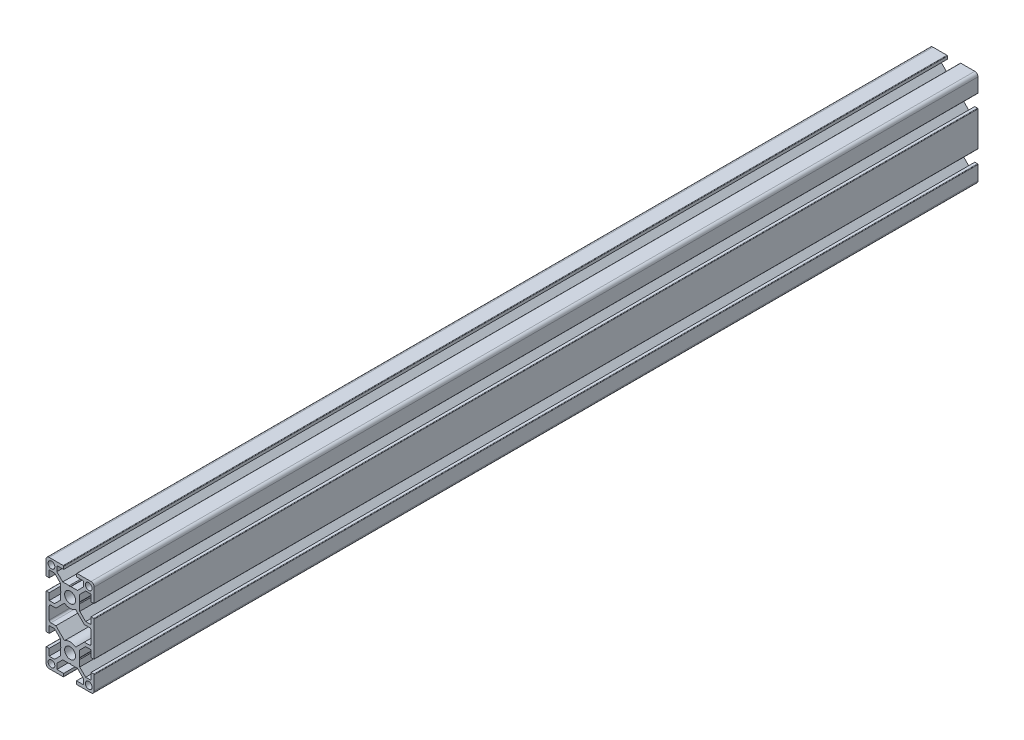
from build123d import *

# Parameters (mm, degrees)
SKETCH1_R           = 2.1
SKETCH1_R_2         = 3.4
BOSS_EXTRUDE1_DEPTH = 550


with BuildPart() as part:
    # Sketch1 → Boss-Extrude1 (new body)
    with BuildSketch(Plane(origin=(0, 0, -1000), x_dir=(-1, 0, 0), z_dir=(0, 0, -1))):
        with BuildLine():
            Line((15, -28), (15, -19.3))
            ThreePointArc((15, -19.3), (14.912132034, -19.087867966), (14.7, -19))
            Line((14.7, -19), (13, -19))
            Line((13, -19), (13, -23.25))
            Line((13, -23.25), (9.6642, -23.25))
            Line((9.6642, -23.25), (6, -19.5858))
            Line((6, -19.5858), (6, -15.519615242))
            Line((6, -15.519615242), (5.7, -15))
            Line((5.7, -15), (6, -14.480384758))
            Line((6, -14.480384758), (6, -10.4142))
            Line((6, -10.4142), (9.6642, -6.75))
            Line((9.6642, -6.75), (13, -6.75))
            Line((13, -6.75), (13, -11))
            Line((13, -11), (14.7, -11))
            ThreePointArc((14.7, -11), (14.912132034, -10.912132034), (15, -10.7))
            Line((15, -10.7), (15, 10.7))
            ThreePointArc((15, 10.7), (14.912132034, 10.912132034), (14.7, 11))
            Line((14.7, 11), (13, 11))
            Line((13, 11), (13, 6.75))
            Line((13, 6.75), (9.6642, 6.75))
            Line((9.6642, 6.75), (6, 10.4142))
            Line((6, 10.4142), (6, 14.480384758))
            Line((6, 14.480384758), (5.7, 15))
            Line((5.7, 15), (6, 15.519615242))
            Line((6, 15.519615242), (6, 19.5858))
            Line((6, 19.5858), (9.6642, 23.25))
            Line((9.6642, 23.25), (13, 23.25))
            Line((13, 23.25), (13, 19))
            Line((13, 19), (14.7, 19))
            ThreePointArc((14.7, 19), (14.912132034, 19.087867966), (15, 19.3))
            Line((15, 19.3), (15, 28))
            ThreePointArc((15, 28), (14.414213562, 29.414213562), (13, 30))
            Line((13, 30), (4.3, 30))
            ThreePointArc((4.3, 30), (4.087867966, 29.912132034), (4, 29.7))
            Line((4, 29.7), (4, 28))
            Line((4, 28), (8.25, 28))
            Line((8.25, 28), (8.25, 24.6642))
            Line((8.25, 24.6642), (4.5858, 21))
            Line((4.5858, 21), (0.519615242, 21))
            Line((0.519615242, 21), (0, 20.7))
            Line((0, 20.7), (-0.519615242, 21))
            Line((-0.519615242, 21), (-4.5858, 21))
            Line((-4.5858, 21), (-8.25, 24.6642))
            Line((-8.25, 24.6642), (-8.25, 28))
            Line((-8.25, 28), (-4, 28))
            Line((-4, 28), (-4, 29.7))
            ThreePointArc((-4, 29.7), (-4.087867966, 29.912132034), (-4.3, 30))
            Line((-4.3, 30), (-13, 30))
            ThreePointArc((-13, 30), (-14.414213562, 29.414213562), (-15, 28))
            Line((-15, 28), (-15, 19.3))
            ThreePointArc((-15, 19.3), (-14.912132034, 19.087867966), (-14.7, 19))
            Line((-14.7, 19), (-13, 19))
            Line((-13, 19), (-13, 23.25))
            Line((-13, 23.25), (-9.6642, 23.25))
            Line((-9.6642, 23.25), (-6, 19.5858))
            Line((-6, 19.5858), (-6, 15.519615242))
            Line((-6, 15.519615242), (-5.7, 15))
            Line((-5.7, 15), (-6, 14.480384758))
            Line((-6, 14.480384758), (-6, 10.4142))
            Line((-6, 10.4142), (-9.6642, 6.75))
            Line((-9.6642, 6.75), (-13, 6.75))
            Line((-13, 6.75), (-13, 11))
            Line((-13, 11), (-14.7, 11))
            ThreePointArc((-14.7, 11), (-14.912132034, 10.912132034), (-15, 10.7))
            Line((-15, 10.7), (-15, -10.7))
            ThreePointArc((-15, -10.7), (-14.912132034, -10.912132034), (-14.7, -11))
            Line((-14.7, -11), (-13, -11))
            Line((-13, -11), (-13, -6.75))
            Line((-13, -6.75), (-9.6642, -6.75))
            Line((-9.6642, -6.75), (-6, -10.4142))
            Line((-6, -10.4142), (-6, -14.480384758))
            Line((-6, -14.480384758), (-5.7, -15))
            Line((-5.7, -15), (-6, -15.519615242))
            Line((-6, -15.519615242), (-6, -19.5858))
            Line((-6, -19.5858), (-9.6642, -23.25))
            Line((-9.6642, -23.25), (-13, -23.25))
            Line((-13, -23.25), (-13, -19))
            Line((-13, -19), (-14.7, -19))
            ThreePointArc((-14.7, -19), (-14.912132034, -19.087867966), (-15, -19.3))
            Line((-15, -19.3), (-15, -28))
            ThreePointArc((-15, -28), (-14.414213562, -29.414213562), (-13, -30))
            Line((-13, -30), (-4.3, -30))
            ThreePointArc((-4.3, -30), (-4.087867966, -29.912132034), (-4, -29.7))
            Line((-4, -29.7), (-4, -28))
            Line((-4, -28), (-8.25, -28))
            Line((-8.25, -28), (-8.25, -24.6642))
            Line((-8.25, -24.6642), (-4.5858, -21))
            Line((-4.5858, -21), (-0.519615242, -21))
            Line((-0.519615242, -21), (0, -20.7))
            Line((0, -20.7), (0.519615242, -21))
            Line((0.519615242, -21), (4.5858, -21))
            Line((4.5858, -21), (8.25, -24.6642))
            Line((8.25, -24.6642), (8.25, -28))
            Line((8.25, -28), (4, -28))
            Line((4, -28), (4, -29.7))
            ThreePointArc((4, -29.7), (4.087867966, -29.912132034), (4.3, -30))
            Line((4.3, -30), (13, -30))
            ThreePointArc((13, -30), (14.414213562, -29.414213562), (15, -28))
        make_face()
        with Locations((11.6, 26.625)):
            Circle(SKETCH1_R, mode=Mode.SUBTRACT)
        with Locations((11.6, -26.625)):
            Circle(SKETCH1_R, mode=Mode.SUBTRACT)
        with Locations((0, -15)):
            Circle(SKETCH1_R_2, mode=Mode.SUBTRACT)
        with Locations((0, 15)):
            Circle(SKETCH1_R_2, mode=Mode.SUBTRACT)
        with Locations((-11.6, 26.625)):
            Circle(SKETCH1_R, mode=Mode.SUBTRACT)
        with Locations((-11.6, -26.625)):
            Circle(SKETCH1_R, mode=Mode.SUBTRACT)
        with BuildLine():
            Line((13, 3.75), (13, -3.75))
            ThreePointArc((13, -3.75), (12.707106781, -4.457106781), (12, -4.75))
            Line((12, -4.75), (8.8358, -4.75))
            Line((8.8358, -4.75), (3.476201279, -10.109598721))
            ThreePointArc((3.476201279, -10.109598721), (0, -9), (-3.476201279, -10.109598721))
            Line((-3.476201279, -10.109598721), (-8.8358, -4.75))
            Line((-8.8358, -4.75), (-12, -4.75))
            ThreePointArc((-12, -4.75), (-12.707106781, -4.457106781), (-13, -3.75))
            Line((-13, -3.75), (-13, 3.75))
            ThreePointArc((-13, 3.75), (-12.707106781, 4.457106781), (-12, 4.75))
            Line((-12, 4.75), (-8.8358, 4.75))
            Line((-8.8358, 4.75), (-3.476201279, 10.109598721))
            ThreePointArc((-3.476201279, 10.109598721), (0, 9), (3.476201279, 10.109598721))
            Line((3.476201279, 10.109598721), (8.8358, 4.75))
            Line((8.8358, 4.75), (12, 4.75))
            ThreePointArc((12, 4.75), (12.707106781, 4.457106781), (13, 3.75))
        make_face(mode=Mode.SUBTRACT)
    extrude(amount=-BOSS_EXTRUDE1_DEPTH)


solid = part.part
